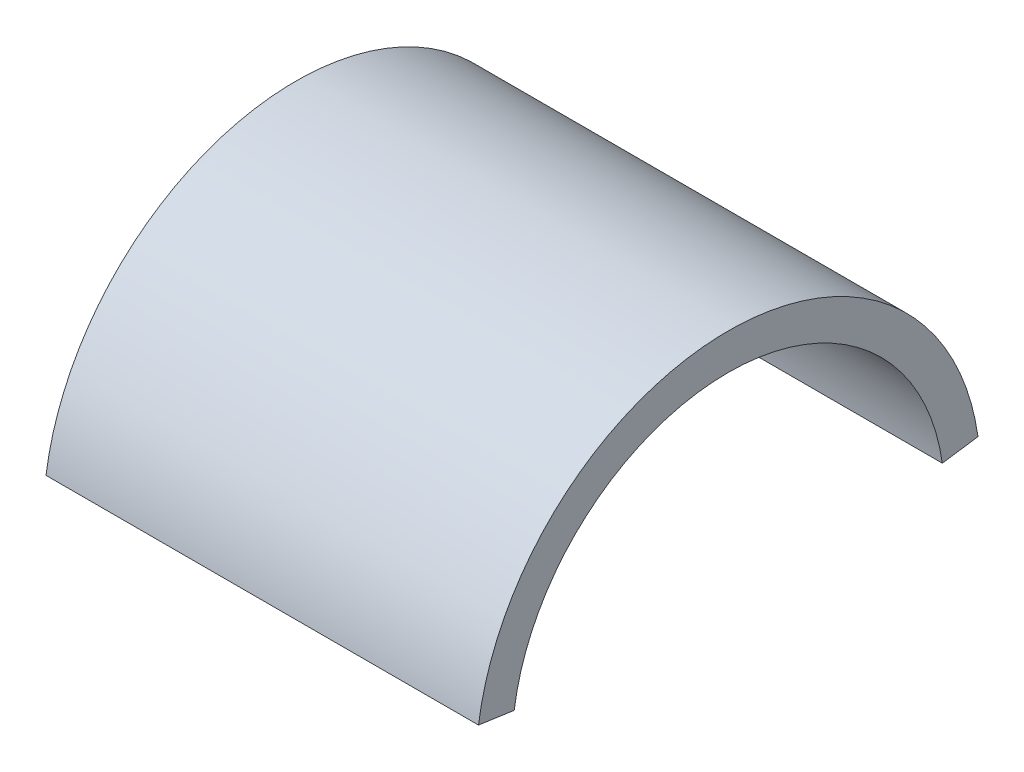
from build123d import *


with BuildPart() as part:
    # Sweep1: sweep along a path in Sketch3
    with BuildLine(Plane(origin=(0, 253.563469884, 36.308182496), x_dir=(1, 0, 0), z_dir=(0, 0.989903076, 0.141745897))) as sweep1_path:
        Line((92.075, 58.903522739), (53.975, 58.903522739))
    # Sketch2 → Sweep1 (sweep)
    with BuildSketch(Plane(origin=(53.975, 0, 0), x_dir=(0, 0, -1), z_dir=(1, 0, 0))):
        with BuildLine():
            Line((-22.000595872, 261.912802567), (-18.857653605, 261.462759343))
            ThreePointArc((-18.857653605, 261.462759343), (0, 277.8125), (18.857653605, 261.462759343))
            Line((18.857653605, 261.462759343), (22.000595872, 261.912802567))
            ThreePointArc((22.000595872, 261.912802567), (0, 280.9875), (-22.000595872, 261.912802567))
        make_face()
    sweep(path=sweep1_path.line)


solid = part.part
